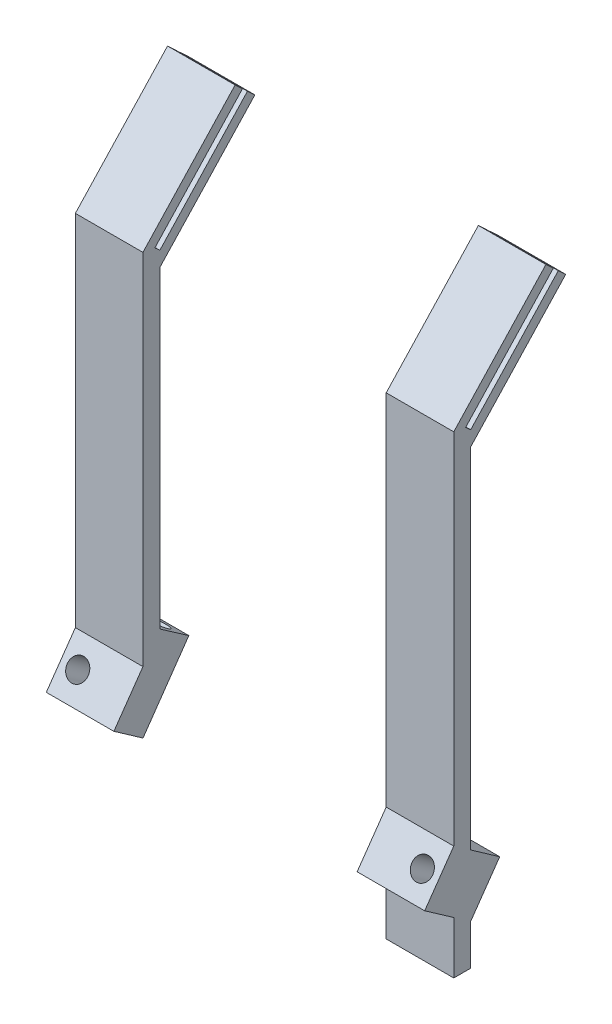
from build123d import *

# Parameters (mm, degrees)
BOSS_EXTRUDE1_DEPTH     = 20
CUT_EXTRUDE1_DEPTH      = 1
CUT_EXTRUDE1_DEPTH_BACK = 21
BOSS_EXTRUDE2_DEPTH     = 20
BOSS_EXTRUDE4_DEPTH     = 10
SKETCH7_R               = 3.1
CUT_EXTRUDE3_DEPTH      = 102.340728726
BOSS_EXTRUDE5_DEPTH     = 10
SKETCH9_R               = 3.1
CUT_EXTRUDE4_DEPTH      = 145.950200236
CUT_EXTRUDE6_DEPTH      = 20
CUT_EXTRUDE7_DEPTH      = 10


with BuildPart() as part:
    # Sketch1 → Boss-Extrude1 (new body)
    with BuildSketch(Plane(origin=(0, 0, 0), x_dir=(0, 0, -1), z_dir=(1, 0, 0))):
        Polygon((0, 0), (-27.279934402, -29.254148065), (-27.279934402, -169.254148065), (-22.279934402, -169.254148065), (-22.279934402, -31.223700443), (3.656768508, -3.4099918), align=None)
    extrude(amount=BOSS_EXTRUDE1_DEPTH)

    # Sketch2 → Cut-Extrude1 (cut, two sides)
    with BuildSketch(Plane(origin=(20, 0, 0), x_dir=(0, 0, -1), z_dir=(1, 0, 0))) as cut_extrude1_sk:
        Polygon((2.194061105, -2.04599508), (-23.742641806, -29.859703723), (-22.279934402, -31.223700443), (3.656768508, -3.4099918), align=None)
    extrude(amount=CUT_EXTRUDE1_DEPTH, mode=Mode.SUBTRACT)
    extrude(cut_extrude1_sk.sketch, amount=-CUT_EXTRUDE1_DEPTH_BACK, mode=Mode.SUBTRACT)

    # Sketch3 → Boss-Extrude2 (add)
    with BuildSketch(Plane(origin=(20, 0, 0), x_dir=(0, 0, -1), z_dir=(1, 0, 0))):
        Polygon((3.656768508, -3.4099918), (-22.279934402, -31.223700443), (-20.085873298, -33.269695523), (5.850829613, -5.45598688), align=None)
        Polygon((-22.279934402, -35.622538), (-20.085873298, -33.269695523), (-22.279934402, -31.223700443), align=None)
    extrude(amount=-BOSS_EXTRUDE2_DEPTH)

    # Sketch6 → Boss-Extrude4 (add)
    with BuildSketch(Plane.ZY):
        Polygon((27.279934402, -135.441491542), (27.279934402, -153.753110374), (35.883580948, -147.728772207), align=None)
        Polygon((22.279934402, -138.942529233), (13.676287857, -144.9668674), (22.279934402, -157.254148065), align=None)
    extrude(amount=-BOSS_EXTRUDE4_DEPTH)

    # Sketch7 → Cut-Extrude3 (cut, through all)
    with BuildSketch(Plane(origin=(0, -41.266885928, -58.935220882), x_dir=(-1, 0, 0), z_dir=(0, -0.573576436, -0.819152044))):
        with Locations((-5, -134.094302237)):
            Circle(SKETCH7_R)
    extrude(amount=-CUT_EXTRUDE3_DEPTH, mode=Mode.SUBTRACT)

    # Sketch8 → Boss-Extrude5 (add)
    with BuildSketch(Plane(origin=(20, 0, 0), x_dir=(0, 0, -1), z_dir=(1, 0, 0))):
        Polygon((-27.279934402, -135.441491542), (-27.279934402, -153.753110374), (-22.279934402, -146.61237034), (-13.695141582, -134.273766824), (-22.279934402, -128.300751509), align=None)
        Polygon((-35.883580948, -147.728772207), (-27.279934402, -153.753110374), (-27.279934402, -135.441491542), align=None)
    extrude(amount=-BOSS_EXTRUDE5_DEPTH)

    # Sketch9 → Cut-Extrude4 (cut, through all)
    with BuildSketch(Plane(origin=(0, -115.987262137, 81.215155285), x_dir=(-1, 0, 0), z_dir=(0, -0.819152044, 0.573576436))):
        with Locations((-15, 60.591190556)):
            Circle(SKETCH9_R)
    extrude(amount=-CUT_EXTRUDE4_DEPTH, mode=Mode.SUBTRACT)


with BuildPart() as body_2:
    # Mirror2: mirrored copy
    add(part.part.mirror(Plane(origin=(56, 0, 0), x_dir=(0, 0, 1), z_dir=(1, 0, 0))))


with BuildPart() as part_1:
    add(part.part)

    # Sketch11 → Cut-Extrude6 (cut)
    with BuildSketch(Plane.ZY):
        Polygon((22.279934402, -157.254148065), (27.279934402, -153.753110374), (27.279934402, -169.254148065), (22.279934402, -169.254148065), align=None)
    extrude(amount=-CUT_EXTRUDE6_DEPTH, mode=Mode.SUBTRACT)

    # Sketch12 → Cut-Extrude7 (cut)
    with BuildSketch(Plane(origin=(20, 0, 0), x_dir=(0, 0, -1), z_dir=(1, 0, 0))):
        Polygon((-22.279934402, -157.254148065), (-22.279934402, -146.61237034), (-27.258612912, -153.768039842), align=None)
    extrude(amount=-CUT_EXTRUDE7_DEPTH, mode=Mode.SUBTRACT)


solid = Compound([body_2.part, part_1.part])
